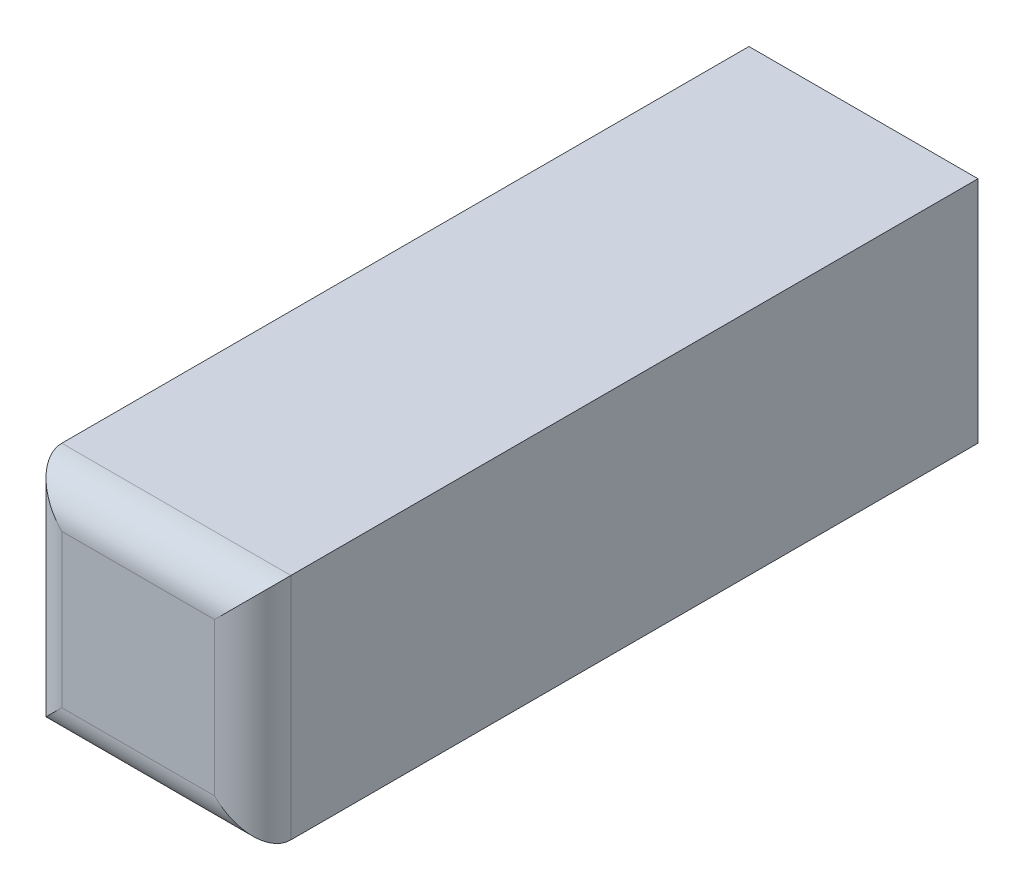
from build123d import *

# Parameters (mm, degrees)
SKETCH1_W           = 6
SKETCH1_H           = 6
BOSS_EXTRUDE1_DEPTH = 19
SKETCH2_R           = 1.8
CUT_EXTRUDE1_DEPTH  = 5
FILLET1_R           = 1


with BuildPart() as part:
    # Sketch1 → Boss-Extrude1 (new body)
    with BuildSketch(Plane.XY):
        Rectangle(SKETCH1_W, SKETCH1_H)
    extrude(amount=BOSS_EXTRUDE1_DEPTH)

    # Sketch2 → Cut-Extrude1 (cut)
    with BuildSketch(Plane(origin=(0, 0, 0), x_dir=(-1, 0, 0), z_dir=(0, 0, -1))):
        Circle(SKETCH2_R)
    extrude(amount=-CUT_EXTRUDE1_DEPTH, mode=Mode.SUBTRACT)

    # Fillet1
    fillet1_edges = [part.edges().sort_by_distance(p)[0] for p in [
        (3, 0, 19),
        (0, 3, 19),
        (-3, 0, 19),
        (0, -3, 19),
    ]]
    fillet(fillet1_edges, radius=FILLET1_R)


solid = part.part
